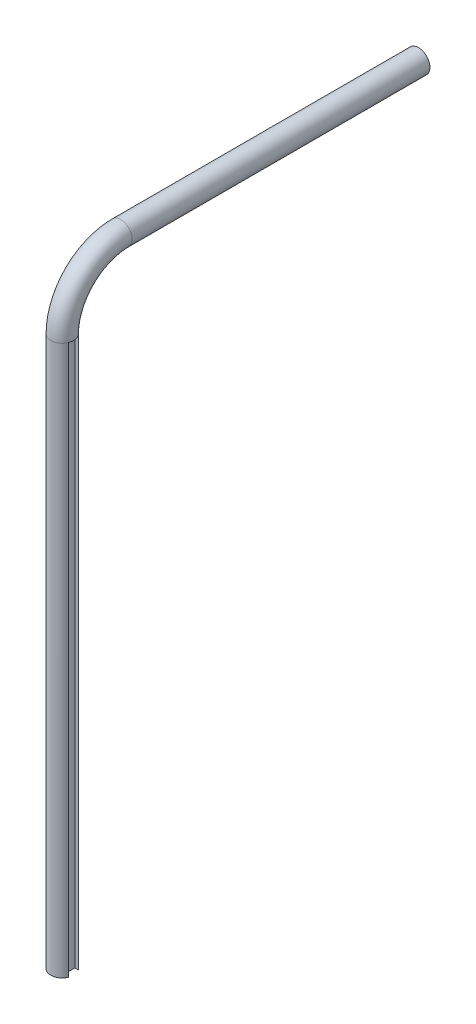
from build123d import *

# Parameters (mm, degrees)
SKETCH3_R           = 12.7
SKETCH3_R_2         = 4.7625
SKETCH4_R           = 12.7
SKETCH4_R_2         = 4.7625
BOSS_EXTRUDE3_DEPTH = 609.6
SKETCH5_R           = 12.7
SKETCH5_R_2         = 4.7625
BOSS_EXTRUDE4_DEPTH = 330.2
SKETCH7_W           = 12.7
SKETCH7_H           = 609.6
CUT_EXTRUDE2_DEPTH  = 6.35


with BuildPart() as part:
    # Sweep1: sweep along a path in Sketch2
    with BuildLine(Plane(origin=(0, 0, 0), x_dir=(0, 0, -1), z_dir=(1, 0, 0))) as sweep1_path:
        ThreePointArc((-64.833774642, 0), (-45.844401699, 45.844401699), (0, 64.833774642))
    # Sketch3 → Sweep1 (sweep)
    with BuildSketch(Plane(origin=(0, 0, 0), x_dir=(1, 0, 0), z_dir=(0, 1, 0))):
        with Locations((0, -64.833774642)):
            Circle(SKETCH3_R)
        with Locations((0, -64.833774642)):
            Circle(SKETCH3_R_2, mode=Mode.SUBTRACT)
    sweep(path=sweep1_path.line)

    # Sketch4 → Boss-Extrude3 (add)
    with BuildSketch(Plane(origin=(0, 0, 0), x_dir=(-1, 0, 0), z_dir=(0, -1, 0))):
        with Locations((0, -64.833774642)):
            Circle(SKETCH4_R)
        with Locations((0, -64.833774642)):
            Circle(SKETCH4_R_2, mode=Mode.SUBTRACT)
    extrude(amount=BOSS_EXTRUDE3_DEPTH)

    # Sketch5 → Boss-Extrude4 (add)
    with BuildSketch(Plane(origin=(0, 0, 0), x_dir=(-1, 0, 0), z_dir=(0, 0, -1))):
        with Locations((0, 64.833774642)):
            Circle(SKETCH5_R)
        with Locations((0, 64.833774642)):
            Circle(SKETCH5_R_2, mode=Mode.SUBTRACT)
    extrude(amount=BOSS_EXTRUDE4_DEPTH)

    # Sketch7 → Cut-Extrude2 (cut)
    with BuildSketch(Plane(origin=(12.7, 0, 0), x_dir=(0, 0, -1), z_dir=(1, 0, 0))):
        with Locations((-63.5, -304.8)):
            Rectangle(SKETCH7_W, SKETCH7_H)
    extrude(amount=-CUT_EXTRUDE2_DEPTH, mode=Mode.SUBTRACT)


solid = part.part
